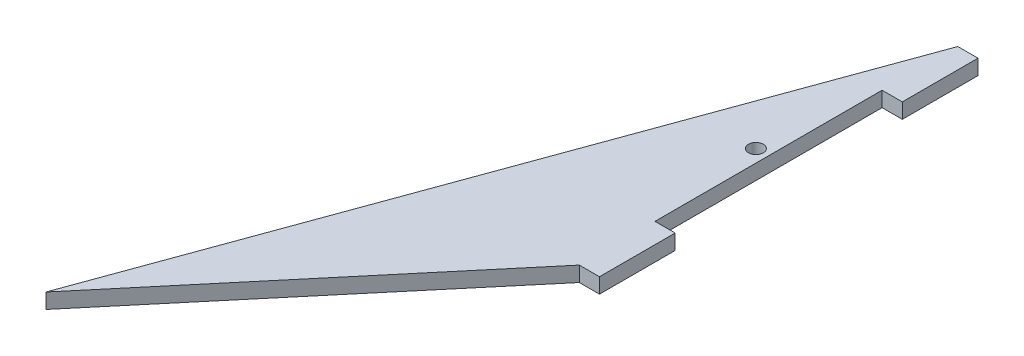
from build123d import *

# Parameters (mm, degrees)
BOSS_EXTRUDE1_DEPTH = 3
SKETCH2_W           = 15
SKETCH2_H           = 3
BOSS_EXTRUDE2_DEPTH = 4
SKETCH3_R           = 1.4732
CUT_EXTRUDE1_DEPTH  = 4


with BuildPart() as part:
    # Sketch1 → Boss-Extrude1 (new body)
    with BuildSketch(Plane(origin=(0, 0, 0), x_dir=(1, 0, 0), z_dir=(0, 1, 0))):
        Polygon((-48.209070726, -57.453333234), (0, 75), (0, 0), align=None)
    extrude(amount=BOSS_EXTRUDE1_DEPTH)

    # Sketch2 → Boss-Extrude2 (add)
    with BuildSketch(Plane(origin=(0, 0, 0), x_dir=(0, 0, -1), z_dir=(1, 0, 0))):
        with Locations((7.5, 1.5)):
            Rectangle(SKETCH2_W, SKETCH2_H)
        with Locations((67.5, 1.5)):
            Rectangle(SKETCH2_W, SKETCH2_H)
    extrude(amount=BOSS_EXTRUDE2_DEPTH)

    # Sketch3 → Cut-Extrude1 (cut, through all)
    with BuildSketch(Plane(origin=(0, 3, 0), x_dir=(1, 0, 0), z_dir=(0, 1, 0))):
        with Locations((-2.5, 37.5)):
            Circle(SKETCH3_R)
    extrude(amount=-CUT_EXTRUDE1_DEPTH, mode=Mode.SUBTRACT)


solid = part.part
